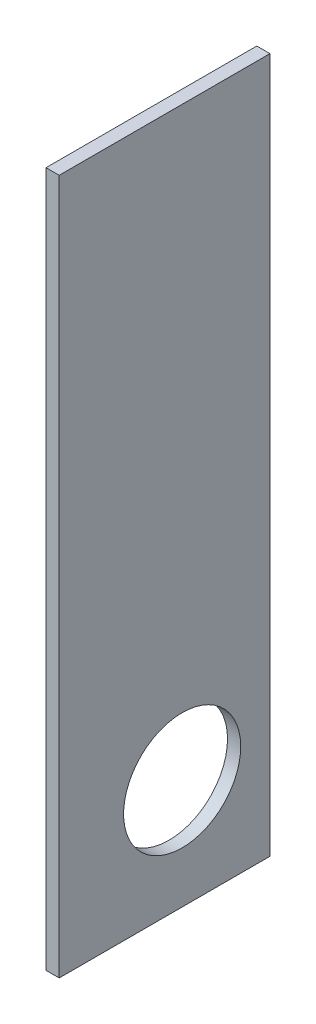
from build123d import *

# Parameters (mm, degrees)
SKETCH1_W           = 288
SKETCH1_H           = 950
BOSS_EXTRUDE1_DEPTH = 18
SKETCH2_R           = 80
CUT_EXTRUDE1_DEPTH  = 19


with BuildPart() as part:
    # Sketch1 → Boss-Extrude1 (new body)
    with BuildSketch(Plane(origin=(0, 0, 0), x_dir=(0, 0, -1), z_dir=(1, 0, 0))):
        with Locations((-123.607933189, -417.219556499)):
            Rectangle(SKETCH1_W, SKETCH1_H)
    extrude(amount=BOSS_EXTRUDE1_DEPTH)

    # Sketch2 → Cut-Extrude1 (cut, through all)
    with BuildSketch(Plane(origin=(18, 0, 0), x_dir=(0, 0, -1), z_dir=(1, 0, 0))):
        with Locations((-99.607933189, -742.219556499)):
            Circle(SKETCH2_R)
    extrude(amount=-CUT_EXTRUDE1_DEPTH, mode=Mode.SUBTRACT)


solid = part.part
